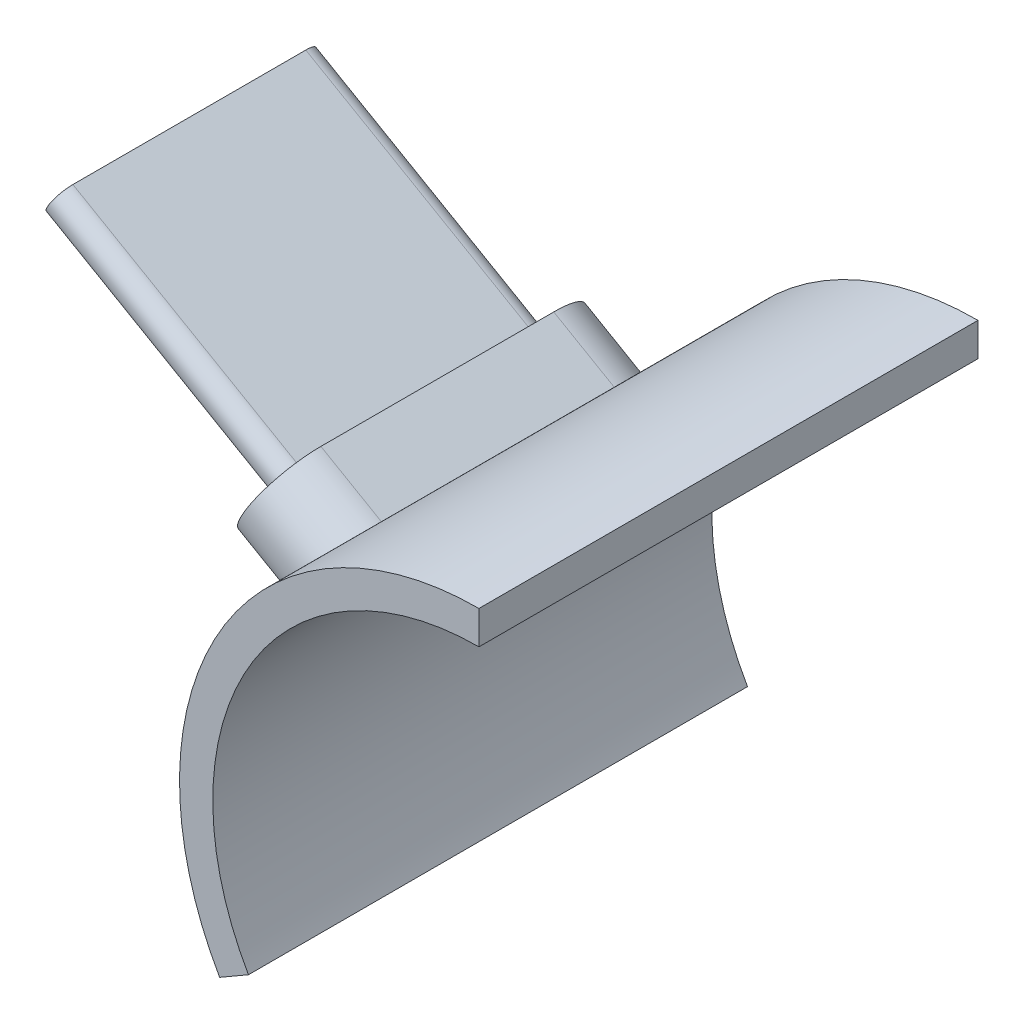
from build123d import *

# Parameters (mm, degrees)
BOSS_EXTRU_1_DEPTH = 15
BOSS_EXTRU_2_START = -0.0139
BOSS_EXTRU_2_DEPTH = 10.0139
BOSS_EXTRU_4_START = -0.134477
BOSS_EXTRU_4_DEPTH = 2.134477


with BuildPart() as part:
    # Esquisse1 → Boss.-Extru.1 (new body)
    with BuildSketch(Plane.XY):
        with BuildLine():
            Line((-7.794228634, -4.5), (-6.92820323, -4))
            ThreePointArc((-6.92820323, -4), (-6.92820323, 4), (0, 8))
            Line((0, 8), (0, 9))
            ThreePointArc((0, 9), (-7.794228634, 4.5), (-7.794228634, -4.5))
        make_face()
    extrude(amount=-BOSS_EXTRU_1_DEPTH)

    # Esquisse2 → Boss.-Extru.2 (add)
    with BuildSketch(Plane(origin=(-7.794228634, 4.5, 0), x_dir=(0, 0, 1), z_dir=(-0.866025404, 0.5, 0)).offset(BOSS_EXTRU_2_START)):
        with BuildLine():
            Line((-11, 0.5), (-4, 0.5))
            ThreePointArc((-4, 0.5), (-3.5, 0), (-4, -0.5))
            Line((-4, -0.5), (-11, -0.5))
            ThreePointArc((-11, -0.5), (-11.5, 0), (-11, 0.5))
        make_face()
    extrude(amount=BOSS_EXTRU_2_DEPTH)

    # Esquisse7 → Boss.-Extru.4 (add)
    with BuildSketch(Plane(origin=(-7.794228634, 4.5, 0), x_dir=(0, 0, 1), z_dir=(-0.866025404, 0.5, 0)).offset(BOSS_EXTRU_4_START)):
        with BuildLine():
            Line((-4, 1.55), (-11, 1.55))
            ThreePointArc((-11, 1.55), (-12.55, 0), (-11, -1.55))
            Line((-11, -1.55), (-4, -1.55))
            ThreePointArc((-4, -1.55), (-2.45, 0), (-4, 1.55))
        make_face()
    extrude(amount=BOSS_EXTRU_4_DEPTH)


solid = part.part
